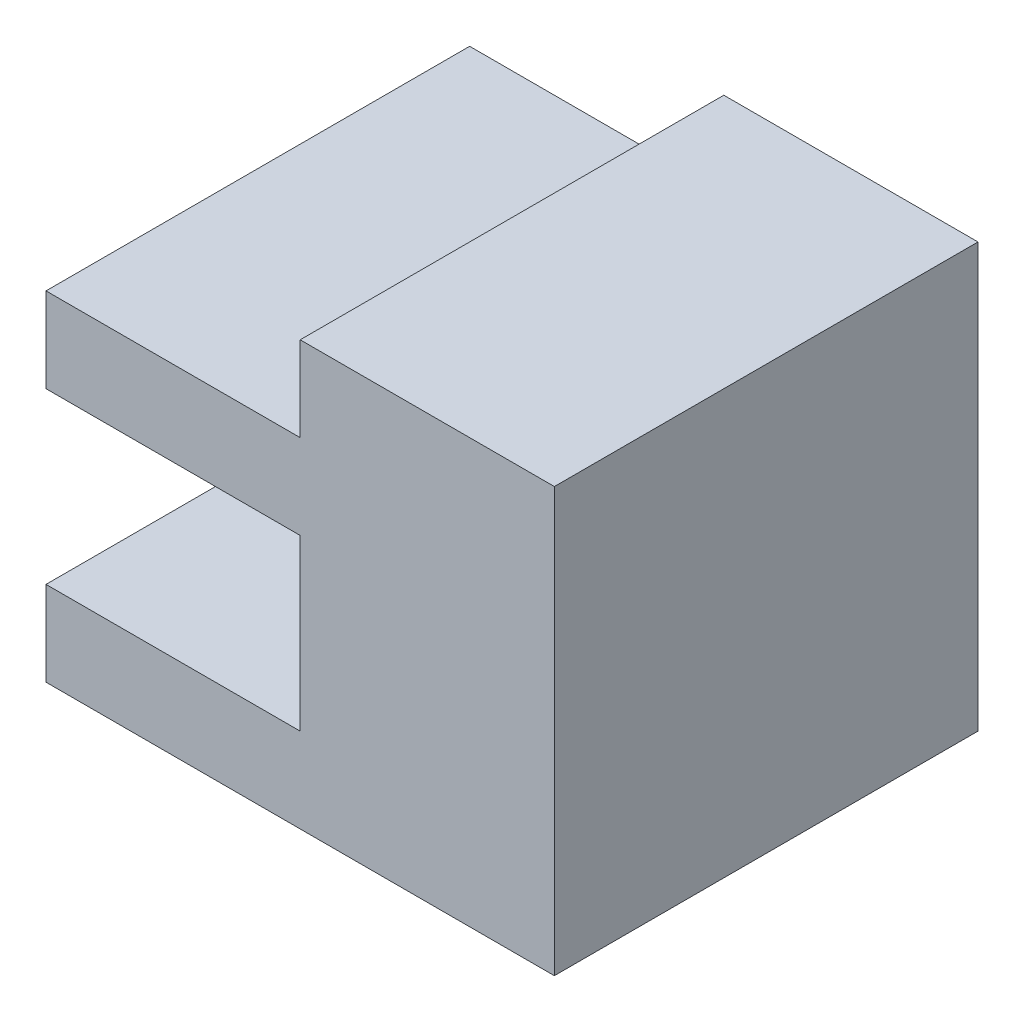
from build123d import *

# Parameters (mm, degrees)
BOSS_EXTRUDE1_DEPTH = 25


with BuildPart() as part:
    # Sketch1 → Boss-Extrude1 (new body)
    with BuildSketch(Plane.XY):
        Polygon((-30, 20), (-15, 20), (-15, 25), (0, 25), (0, 0), (-30, 0), (-30, 5), (-15, 5), (-15, 15), (-30, 15), align=None)
    extrude(amount=BOSS_EXTRUDE1_DEPTH)


solid = part.part
